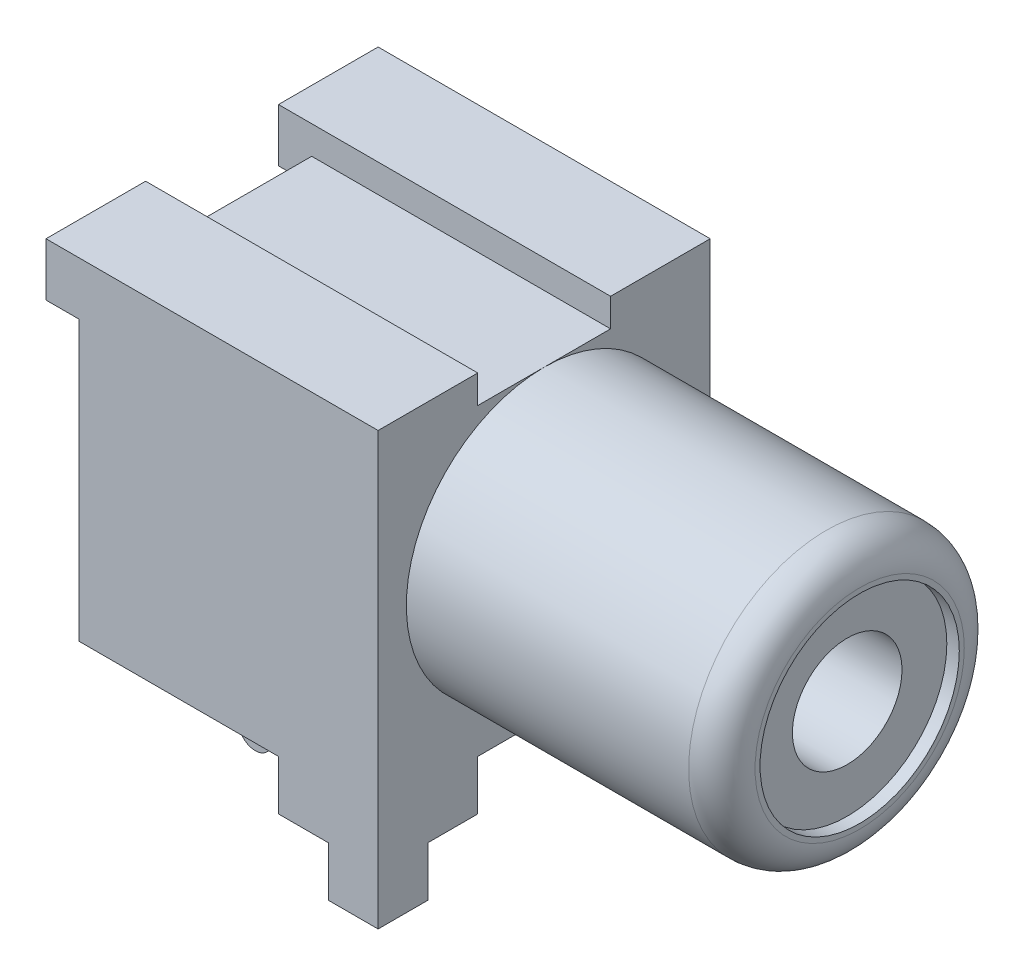
from build123d import *

# Parameters (mm, degrees)
ESBO_O1_W                                            = 10
ESBO_O1_H                                            = 11.5
RESSALTO_EXTRUS_O1_DEPTH                             = 9
ESBO_O2_W                                            = 4
ESBO_O2_H                                            = 0.85
CORTE_EXTRUS_O1_DEPTH                                = 10
ESBO_O3_W                                            = 3
ESBO_O3_H                                            = 1.6
RESSALTO_EXTRUS_O2_DEPTH                             = 1
ESBO_O4_W                                            = 3
ESBO_O4_H                                            = 1.6
RESSALTO_EXTRUS_O3_DEPTH                             = 1
ESBO_O5_W                                            = 4
ESBO_O5_H                                            = 1.5
CORTE_EXTRUS_O2_DEPTH                                = 11
ESBO_O6_W                                            = 1.5
ESBO_O6_H                                            = 1
RESSALTO_EXTRUS_O4_DEPTH                             = 1
ESBO_O7_W                                            = 1.5
ESBO_O7_H                                            = 1.5
CORTE_EXTRUS_O3_DEPTH                                = 6
ESBO_O8_W                                            = 1.5
ESBO_O8_H                                            = 1
RESSALTO_EXTRUS_O5_DEPTH                             = 1
ESBO_O9_W                                            = 1.5
ESBO_O9_H                                            = 1.5
CORTE_EXTRUS_O4_DEPTH                                = 6
ESBO_O10_W                                           = 1.5
ESBO_O10_H                                           = 1.5
RESSALTO_EXTRUS_O6_DEPTH                             = 1.5
ESBO_O11_W                                           = 1.5
ESBO_O11_H                                           = 1.5
RESSALTO_EXTRUS_O7_DEPTH                             = 1.5
ESBO_O12_W                                           = 9.5
ESBO_O12_H                                           = 4.15
REBAIXO_PARA_PARAFUSO_DE_M_QUINA_DE_CABE_D           = 3.3
REBAIXO_PARA_PARAFUSO_DE_M_QUINA_DE_CABE_DEPTH       = 9.5
REBAIXO_PARA_PARAFUSO_DE_M_QUINA_DE_CABE_CBORE_D     = 6
REBAIXO_PARA_PARAFUSO_DE_M_QUINA_DE_CABE_CBORE_DEPTH = 0.375
FILETE1_R                                            = 1
RESSALTO_EXTRUS_O9_DEPTH                             = 0.2


with BuildPart() as part:
    # Esboço1 → Ressalto-extrusão1 (new body)
    with BuildSketch(Plane(origin=(10, 0, 0), x_dir=(0, 0, -1), z_dir=(1, 0, 0))):
        with Locations((0, -0.75)):
            Rectangle(ESBO_O1_W, ESBO_O1_H)
    extrude(amount=-RESSALTO_EXTRUS_O1_DEPTH)

    # Esboço2 → Corte-extrusão1 (cut, through all)
    with BuildSketch(Plane(origin=(10, 0, 0), x_dir=(0, 0, -1), z_dir=(1, 0, 0))):
        with Locations((0, 4.575)):
            Rectangle(ESBO_O2_W, ESBO_O2_H)
    extrude(amount=-CORTE_EXTRUS_O1_DEPTH, mode=Mode.SUBTRACT)

    # Esboço3 → Ressalto-extrusão2 (add)
    with BuildSketch(Plane.ZY.offset(-1)):
        with Locations((3.5, 4.2)):
            Rectangle(ESBO_O3_W, ESBO_O3_H)
    extrude(amount=RESSALTO_EXTRUS_O2_DEPTH)

    # Esboço4 → Ressalto-extrusão3 (add)
    with BuildSketch(Plane.ZY.offset(-1)):
        with Locations((-3.5, 4.2)):
            Rectangle(ESBO_O4_W, ESBO_O4_H)
    extrude(amount=RESSALTO_EXTRUS_O3_DEPTH)

    # Esboço5 → Corte-extrusão2 (cut, through all)
    with BuildSketch(Plane(origin=(10, 0, 0), x_dir=(0, 0, -1), z_dir=(1, 0, 0))):
        with Locations((0, -5.75)):
            Rectangle(ESBO_O5_W, ESBO_O5_H)
    extrude(amount=-CORTE_EXTRUS_O2_DEPTH, mode=Mode.SUBTRACT)

    # Esboço6 → Ressalto-extrusão4 (add)
    with BuildSketch(Plane.ZY.offset(-1)):
        with Locations((2.75, -6)):
            Rectangle(ESBO_O6_W, ESBO_O6_H)
    extrude(amount=RESSALTO_EXTRUS_O4_DEPTH)

    # Esboço7 → Corte-extrusão3 (cut)
    with BuildSketch(Plane.ZY.offset(-1)):
        with Locations((4.25, -5.75)):
            Rectangle(ESBO_O7_W, ESBO_O7_H)
    extrude(amount=-CORTE_EXTRUS_O3_DEPTH, mode=Mode.SUBTRACT)

    # Esboço8 → Ressalto-extrusão5 (add)
    with BuildSketch(Plane.ZY.offset(-1)):
        with Locations((-2.75, -6)):
            Rectangle(ESBO_O8_W, ESBO_O8_H)
    extrude(amount=RESSALTO_EXTRUS_O5_DEPTH)

    # Esboço9 → Corte-extrusão4 (cut)
    with BuildSketch(Plane.ZY.offset(-1)):
        with Locations((-4.25, -5.75)):
            Rectangle(ESBO_O9_W, ESBO_O9_H)
    extrude(amount=-CORTE_EXTRUS_O4_DEPTH, mode=Mode.SUBTRACT)

    # Esboço10 → Ressalto-extrusão6 (add)
    with BuildSketch(Plane.XZ.offset(6.5)):
        with Locations((9.25, 4.25)):
            Rectangle(ESBO_O10_W, ESBO_O10_H)
    extrude(amount=RESSALTO_EXTRUS_O6_DEPTH)

    # Esboço11 → Ressalto-extrusão7 (add)
    with BuildSketch(Plane.XZ.offset(6.5)):
        with Locations((9.25, -4.25)):
            Rectangle(ESBO_O11_W, ESBO_O11_H)
    extrude(amount=RESSALTO_EXTRUS_O7_DEPTH)

    # Esboço12 → Revolução1 (revolve)
    with BuildSketch(Plane.XY):
        with Locations((14.75, 2.075)):
            Rectangle(ESBO_O12_W, ESBO_O12_H)
    revolve(axis=Axis((10, 0, 0), (1, 0, 0)))

    # Rebaixo para parafuso de máquina de cabeça sextavada de M31
    with Locations(Plane(origin=(19.5, 0, 0), x_dir=(0, 0, -1), z_dir=(1, 0, 0))):
        with Locations((0, 0)):
            CounterBoreHole(REBAIXO_PARA_PARAFUSO_DE_M_QUINA_DE_CABE_D / 2, REBAIXO_PARA_PARAFUSO_DE_M_QUINA_DE_CABE_CBORE_D / 2, REBAIXO_PARA_PARAFUSO_DE_M_QUINA_DE_CABE_CBORE_DEPTH, depth=REBAIXO_PARA_PARAFUSO_DE_M_QUINA_DE_CABE_DEPTH)

    # Filete1
    filete1_edges = [part.edges().sort_by_distance(p)[0] for p in [
        (19.5, -4.15, 0),
    ]]
    fillet(filete1_edges, radius=FILETE1_R)

    # Esboço16 → Ressalto-extrusão9 (add, symmetric)
    with BuildSketch(Plane(origin=(0, 0, 0), x_dir=(-1, 0, 0), z_dir=(0, 0, -1))):
        with BuildLine():
            Line((-2, -5), (-2, -9.5))
            ThreePointArc((-2, -9.5), (-1.569549144, -9.99513929), (-1.019348334, -9.637746055))
            Line((-1.019348334, -9.637746055), (-0.549999999, -8))
            Line((-0.549999999, -8), (-0.8, -7.928354531))
            Line((-0.8, -7.928354531), (-0.8, 3.5))
            Line((-0.8, 3.5), (-1, 3.5))
            Line((-1, 3.5), (-2, -5))
        make_face()
    extrude(amount=RESSALTO_EXTRUS_O9_DEPTH, both=True)


solid = part.part
